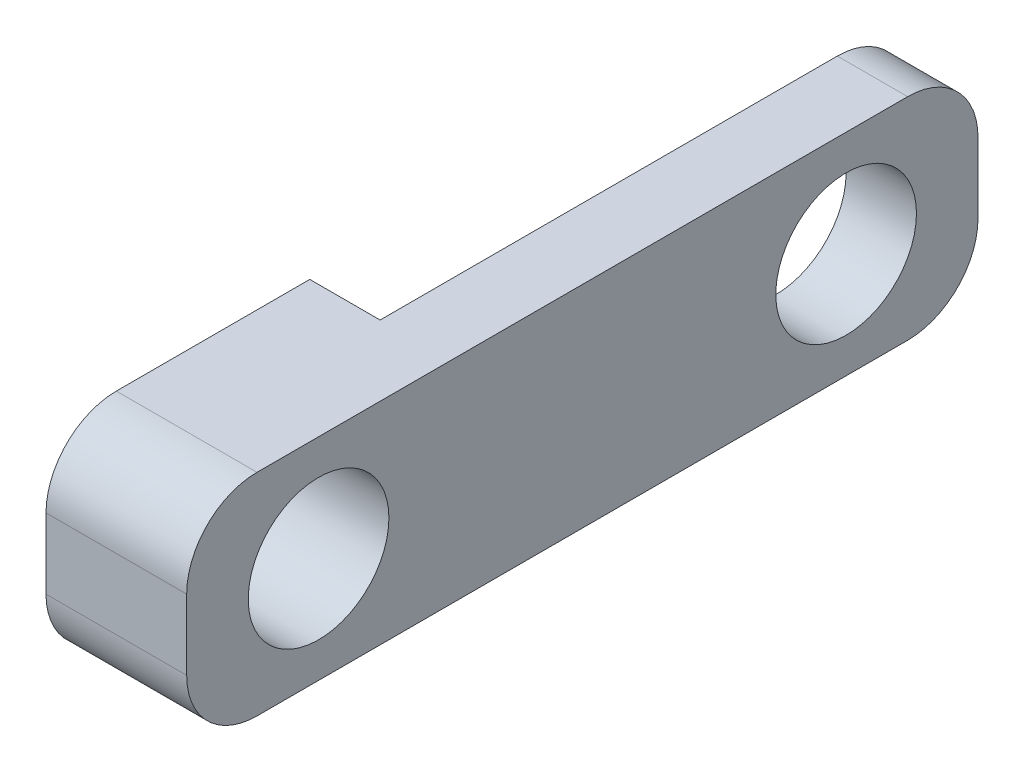
from build123d import *

# Parameters (mm, degrees)
SKETCH1_W           = 45
SKETCH1_H           = 12
BOSS_EXTRUDE1_DEPTH = 8
SKETCH2_R           = 4
CUT_EXTRUDE1_DEPTH  = 8
FILLET1_R           = 4
SKETCH3_W           = 4
SKETCH3_H           = 39.830583049
CUT_EXTRUDE2_DEPTH  = 16


with BuildPart() as part:
    # Sketch1 → Boss-Extrude1 (new body)
    with BuildSketch(Plane(origin=(0, 0, 0), x_dir=(0, 0, -1), z_dir=(1, 0, 0))):
        Rectangle(SKETCH1_W, SKETCH1_H)
    extrude(amount=BOSS_EXTRUDE1_DEPTH)

    # Sketch2 → Cut-Extrude1 (cut)
    with BuildSketch(Plane(origin=(8, 0, 0), x_dir=(0, 0, -1), z_dir=(1, 0, 0))):
        with Locations((-15, 0)):
            Circle(SKETCH2_R)
        with Locations((15, 0)):
            Circle(SKETCH2_R)
    extrude(amount=-CUT_EXTRUDE1_DEPTH, mode=Mode.SUBTRACT)

    # Fillet1
    fillet1_edges = [part.edges().sort_by_distance(p)[0] for p in [
        (4, -6, -22.5),
        (4, -6, 22.5),
        (4, 6, 22.5),
        (4, 6, -22.5),
    ]]
    fillet(fillet1_edges, radius=FILLET1_R)

    # Sketch3 → Cut-Extrude2 (cut)
    with BuildSketch(Plane(origin=(0, 6, 0), x_dir=(1, 0, 0), z_dir=(0, 1, 0))):
        with Locations((2, 12.415291525)):
            Rectangle(SKETCH3_W, SKETCH3_H)
    extrude(amount=-CUT_EXTRUDE2_DEPTH, mode=Mode.SUBTRACT)


solid = part.part
